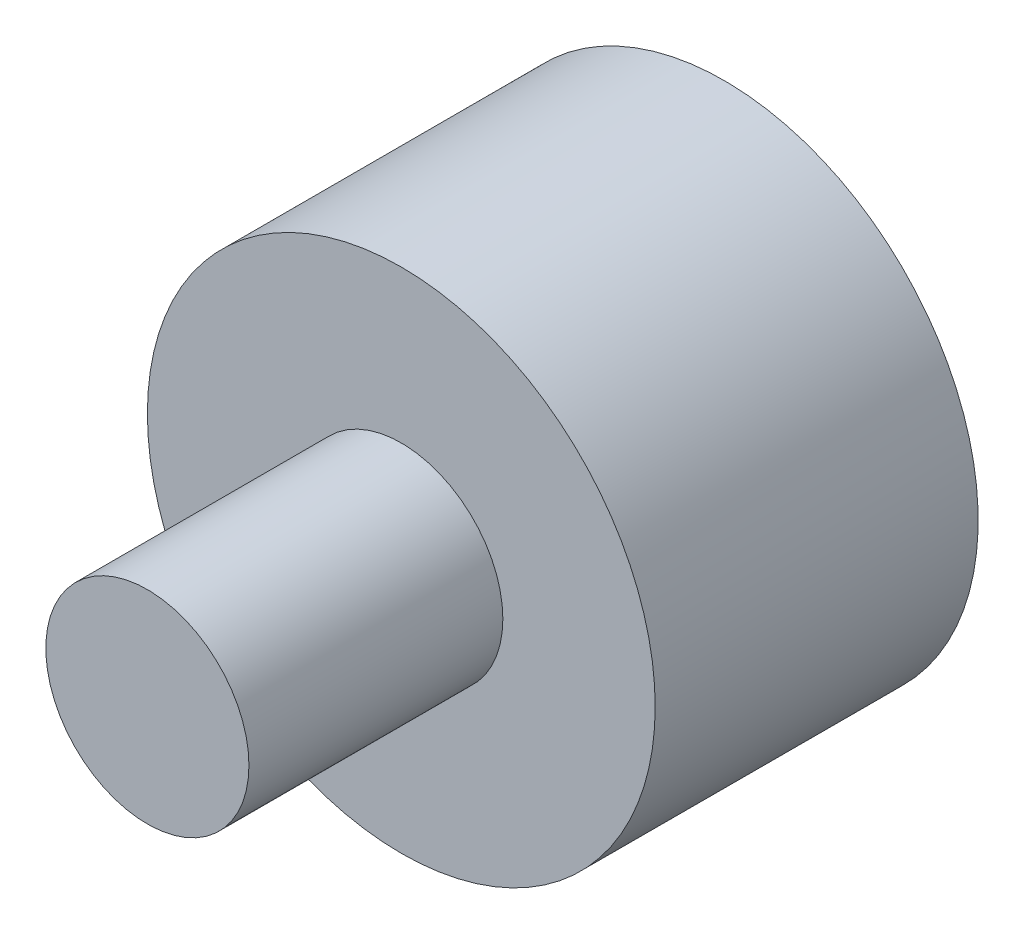
from build123d import *

# Parameters (mm, degrees)
SKETCH1_R           = 5
BOSS_EXTRUDE1_DEPTH = 3.36
SKETCH2_R           = 2
BOSS_EXTRUDE2_DEPTH = 5
SKETCH3_R           = 5
BOSS_EXTRUDE3_DEPTH = 3


with BuildPart() as part:
    # Sketch1 → Boss-Extrude1 (new body)
    with BuildSketch(Plane.XY):
        Circle(SKETCH1_R)
    extrude(amount=BOSS_EXTRUDE1_DEPTH)

    # Sketch2 → Boss-Extrude2 (add)
    with BuildSketch(Plane.XY.offset(3.36)):
        Circle(SKETCH2_R)
    extrude(amount=BOSS_EXTRUDE2_DEPTH)

    # Sketch3 → Boss-Extrude3 (add)
    with BuildSketch(Plane(origin=(0, 0, 0), x_dir=(-1, 0, 0), z_dir=(0, 0, -1))):
        Circle(SKETCH3_R)
    extrude(amount=BOSS_EXTRUDE3_DEPTH)


solid = part.part
